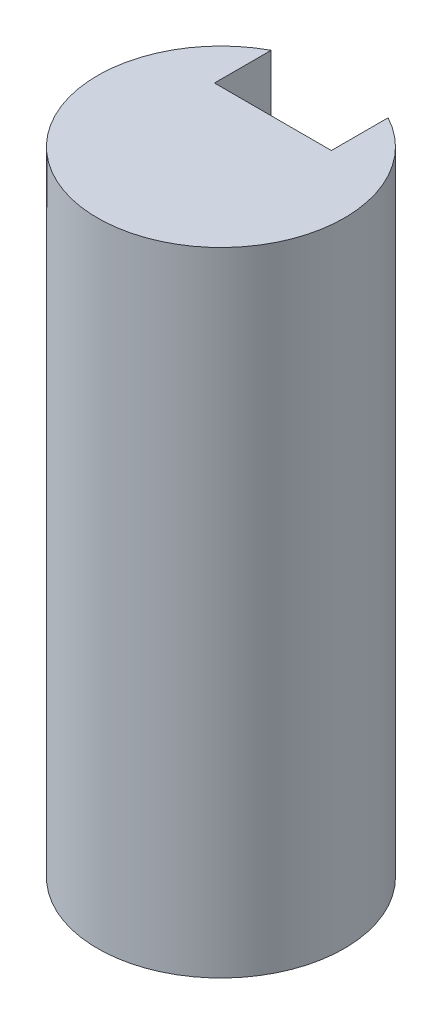
from build123d import *
from build123d.topology import SkipClean

# Parameters (mm, degrees)
BOSS_EXTRUDE1_DEPTH = 12.7
BOSS_EXTRUDE2_DEPTH = 30
BOSS_EXTRUDE3_DEPTH = 6


with BuildPart() as part:
    # Sketch1 → Boss-Extrude1 (new body)
    with BuildSketch(Plane(origin=(0, 0, 0), x_dir=(1, 0, 0), z_dir=(0, 1, 0))):
        with BuildLine():
            Line((4.5, 8.366600265), (4.5, 4))
            Line((4.5, 4), (-4.5, 4))
            Line((-4.5, 4), (-4.5, 8.366600265))
            ThreePointArc((-4.5, 8.366600265), (-4.873397172, -8.154753215), (9.5, 0))
            ThreePointArc((9.5, 0), (8.154753215, 4.873397172), (4.5, 8.366600265))
        make_face()
    extrude(amount=BOSS_EXTRUDE1_DEPTH)

    # Sketch1_3 → Boss-Extrude2 (add)
    with BuildSketch(Plane(origin=(0, 0, 0), x_dir=(1, 0, 0), z_dir=(0, 1, 0))):
        with BuildLine():
            Line((4.5, 8.366600265), (4.5, 4))
            Line((4.5, 4), (-4.5, 4))
            Line((-4.5, 4), (-4.5, 8.366600265))
            ThreePointArc((-4.5, 8.366600265), (-4.873397172, -8.154753215), (9.5, 0))
            ThreePointArc((9.5, 0), (8.154753215, 4.873397172), (4.5, 8.366600265))
        make_face()
        with BuildLine():
            Line((-4.5, 4), (4.5, 4))
            Line((4.5, 4), (4.5, 8.366600265))
            ThreePointArc((4.5, 8.366600265), (0, 9.5), (-4.5, 8.366600265))
            Line((-4.5, 8.366600265), (-4.5, 4))
        make_face()
    extrude(amount=-BOSS_EXTRUDE2_DEPTH)

    # Sketch2 → Boss-Extrude3 (add)
    with SkipClean():  # the faces are left unmerged after this step: merging them gives an invalid solid
        with BuildSketch(Plane.XZ.offset(30)):
            with BuildLine():
                Line((-4.5, -4), (4.5, -4))
                Line((4.5, -4), (4.5, -8.366600265))
                ThreePointArc((4.5, -8.366600265), (8.154753215, -4.873397172), (9.5, 0))
                ThreePointArc((9.5, 0), (-4.873397172, 8.154753215), (-4.5, -8.366600265))
                Line((-4.5, -8.366600265), (-4.5, -4))
            make_face()
        extrude(amount=BOSS_EXTRUDE3_DEPTH)


solid = part.part
